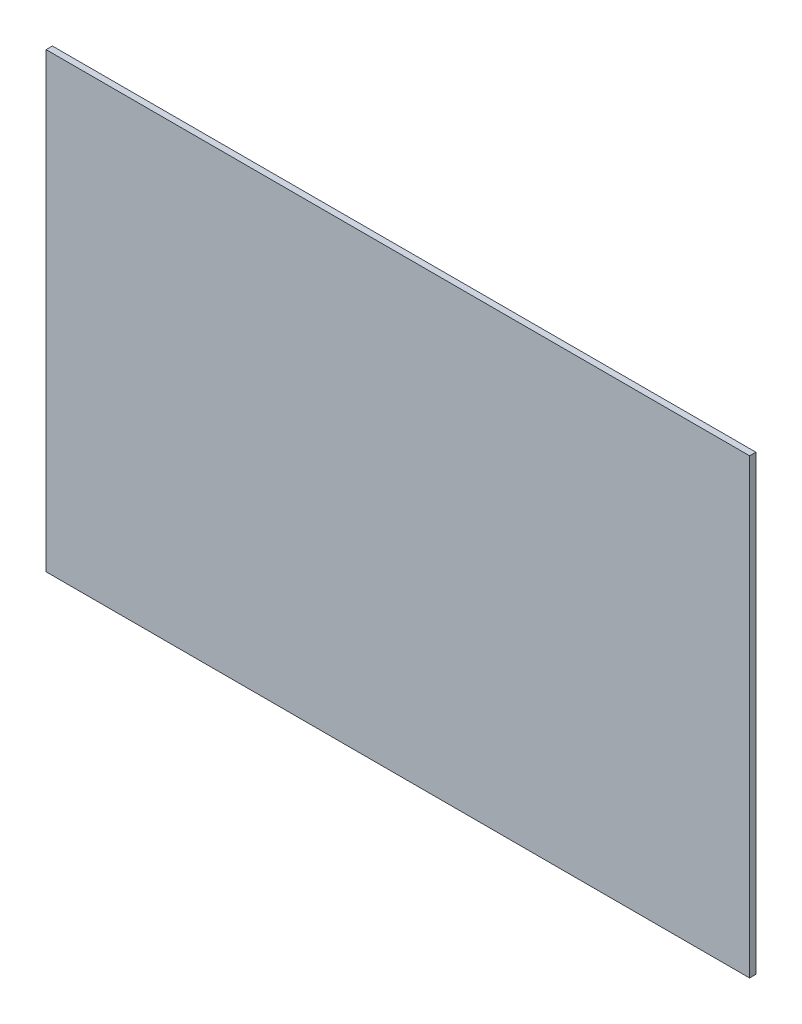
from build123d import *

# Parameters (mm, degrees)
SKETCH1_W           = 355.6
SKETCH1_H           = 228.6
BOSS_EXTRUDE1_DEPTH = 3.175


with BuildPart() as part:
    # Sketch1 → Boss-Extrude1 (new body)
    with BuildSketch(Plane.XY):
        with Locations((177.8, 114.3)):
            Rectangle(SKETCH1_W, SKETCH1_H)
    extrude(amount=BOSS_EXTRUDE1_DEPTH)


solid = part.part
